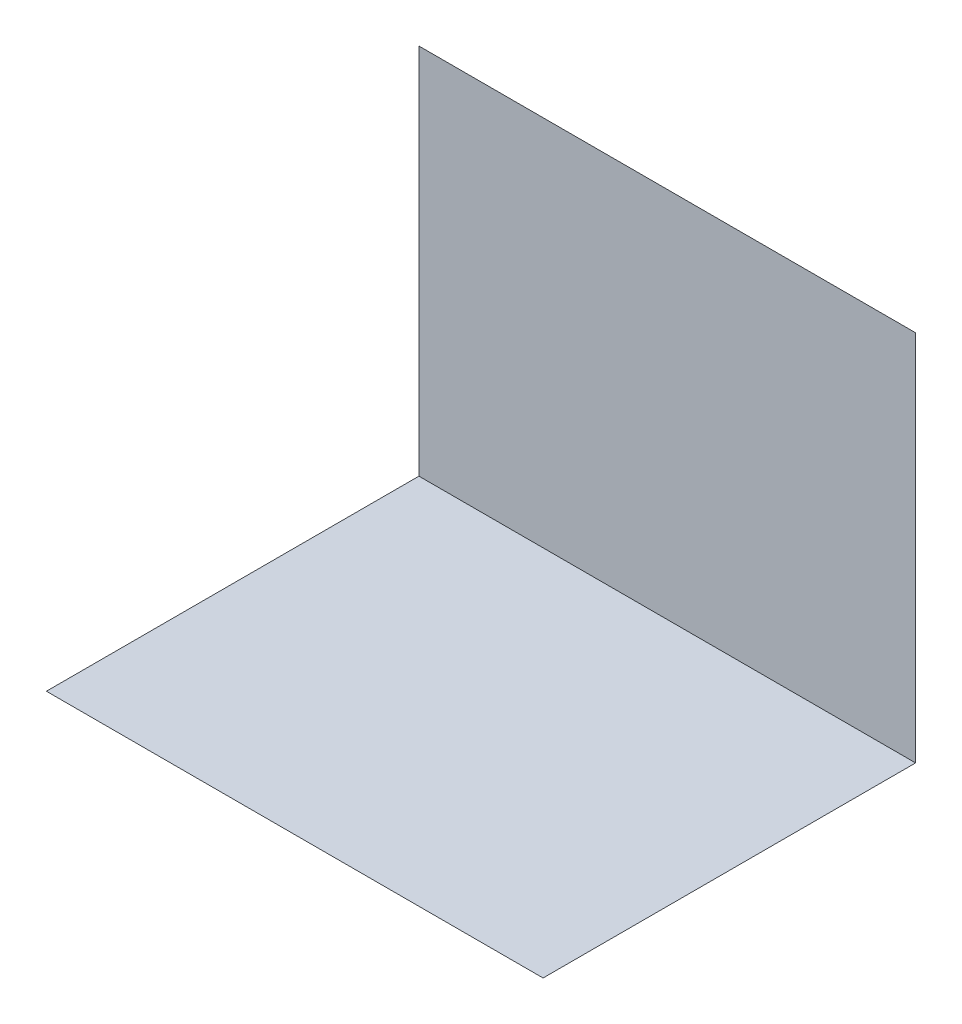
from build123d import *

# Parameters (mm, degrees)
SKETCH1_W      = 200
SKETCH1_H      = 150
EXTRUDE1_DEPTH = 0.0001
SKETCH2_W      = 200
SKETCH2_H      = 150
EXTRUDE2_DEPTH = 0.0001


with BuildPart() as part:
    # Sketch1 → Extrude1 (new body)
    with BuildSketch(Plane.XY):
        with Locations((0, 75)):
            Rectangle(SKETCH1_W, SKETCH1_H)
    extrude(amount=-EXTRUDE1_DEPTH)


with BuildPart() as body_2:
    # Sketch2 → Extrude2 (new body)
    with BuildSketch(Plane(origin=(0, 0, 0), x_dir=(1, 0, 0), z_dir=(0, 1, 0))):
        with Locations((0, -75)):
            Rectangle(SKETCH2_W, SKETCH2_H)
    extrude(amount=-EXTRUDE2_DEPTH)


solid = Compound([part.part, body_2.part])
